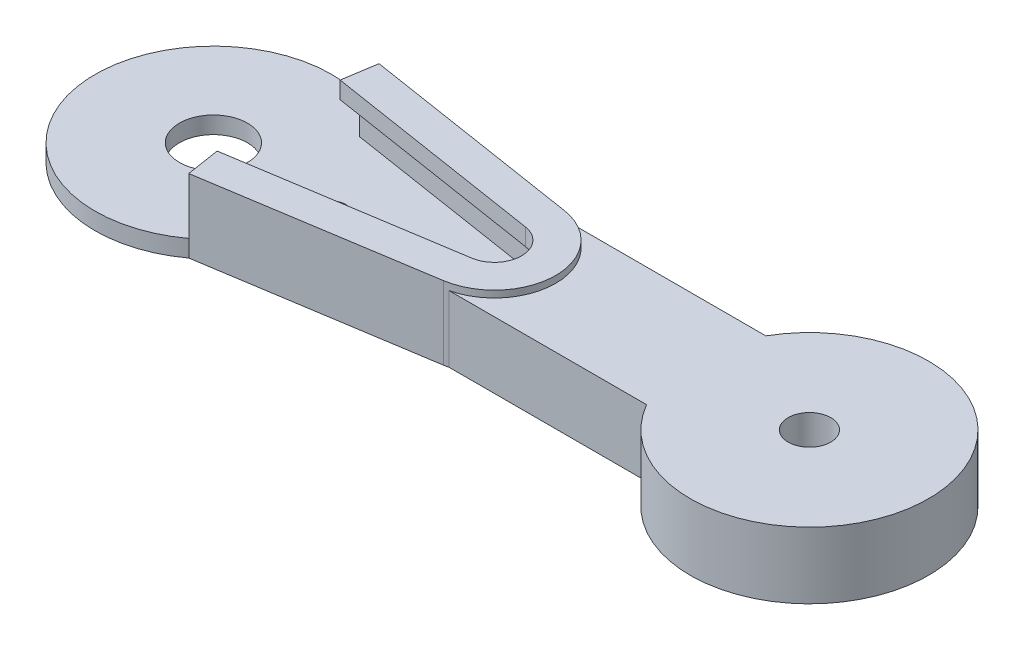
from build123d import *
from build123d.topology import SkipClean

# Parameters (mm, degrees)
SKETCH2_R           = 6
SKETCH2_R_2         = 1.5
BOSS_EXTRUDE1_DEPTH = 1.15
SKETCH3_R           = 4.4
BOSS_EXTRUDE2_DEPTH = 3.2
SKETCH4_R           = 0.75
BOSS_EXTRUDE3_DEPTH = 1.15
CIRPATTERN1_COUNT   = 2
BOSS_EXTRUDE5_DEPTH = 2.3
SKETCH7_R           = 2
BOSS_EXTRUDE6_DEPTH = 1
CUT_EXTRUDE2_DEPTH  = 23.239726126
CUT_EXTRUDE4_DEPTH  = 2.3
SKETCH13_R          = 4.4
CUT_EXTRUDE5_DEPTH  = 3.3
BOSS_EXTRUDE8_DEPTH = 1
SKETCH14_R          = 1.25
BOSS_EXTRUDE9_DEPTH = 3.9


with BuildPart() as part:
    # Sketch2 → Boss-Extrude1 (new, symmetric)
    with BuildSketch(Plane(origin=(0, 0, 0), x_dir=(1, 0, 0), z_dir=(0, 1, 0))):
        with Locations(Location((0, 0, 0), (0, 0, 270))):
            Circle(SKETCH2_R)
        with Locations(Location((0, 0, 0), (0, 0, 270))):
            Circle(SKETCH2_R_2, mode=Mode.SUBTRACT)
    extrude(amount=BOSS_EXTRUDE1_DEPTH, both=True)

    # Sketch3 → Boss-Extrude2 (add)
    with BuildSketch(Plane(origin=(0, 1.15, 0), x_dir=(1, 0, 0), z_dir=(0, 1, 0))):
        with Locations(Location((0, 0, 0), (0, 0, 270))):
            Circle(SKETCH3_R)
        with BuildLine():
            Line((0.107421435, 2.898009771), (0.338399731, 2.678709694))
            Line((0.338399731, 2.678709694), (0.61665913, 2.83367809))
            ThreePointArc((0.61665913, 2.83367809), (0.721200673, 2.808891167), (0.824752316, 2.780248841))
            Line((0.824752316, 2.780248841), (0.993936292, 2.510396512))
            Line((0.993936292, 2.510396512), (1.301992734, 2.591295993))
            ThreePointArc((1.301992734, 2.591295993), (1.397085655, 2.541289372), (1.490260976, 2.48779465))
            Line((1.490260976, 2.48779465), (1.587020181, 2.184345885))
            Line((1.587020181, 2.184345885), (1.905517346, 2.186093238))
            ThreePointArc((1.905517346, 2.186093238), (1.985186607, 2.11400902), (2.062131058, 2.039023173))
            Line((2.062131058, 2.039023173), (2.080385755, 1.721044772))
            Line((2.080385755, 1.721044772), (2.389311295, 1.643530205))
            ThreePointArc((2.389311295, 1.643530205), (2.448550984, 1.553897705), (2.504429862, 1.46213237))
            Line((2.504429862, 1.46213237), (2.443033042, 1.149604087))
            Line((2.443033042, 1.149604087), (2.722976028, 0.997698125))
            ThreePointArc((2.722976028, 0.997698125), (2.758063897, 0.896149284), (2.789366126, 0.793370413))
            Line((2.789366126, 0.793370413), (2.652175577, 0.505929549))
            Line((2.652175577, 0.505929549), (2.885546163, 0.289177003))
            ThreePointArc((2.885546163, 0.289177003), (2.894277512, 0.182092507), (2.899036259, 0.074758075))
            Line((2.899036259, 0.074758075), (2.694672167, -0.169534403))
            Line((2.694672167, -0.169534403), (2.866806821, -0.437514174))
            ThreePointArc((2.866806821, -0.437514174), (2.848633027, -0.543405812), (2.826549281, -0.648551587))
            Line((2.826549281, -0.648551587), (2.567852594, -0.834345885))
            Line((2.567852594, -0.834345885), (2.667935462, -1.136714727))
            ThreePointArc((2.667935462, -1.136714727), (2.623998452, -1.234759946), (2.576459817, -1.331110368))
            Line((2.576459817, -1.331110368), (2.279685399, -1.446732346))
            Line((2.279685399, -1.446732346), (2.301427906, -1.764491312))
            ThreePointArc((2.301427906, -1.764491312), (2.234488404, -1.84852957), (2.164481907, -1.930030589))
            Line((2.164481907, -1.930030589), (1.848277186, -1.968215294))
            Line((1.848277186, -1.968215294), (1.790313171, -2.281398419))
            ThreePointArc((1.790313171, -2.281398419), (1.704577232, -2.346149284), (1.616501638, -2.40767989))
            Line((1.616501638, -2.40767989), (1.30073492, -2.366028036))
            Line((1.30073492, -2.366028036), (1.166706475, -2.654956874))
            ThreePointArc((1.166706475, -2.654956874), (1.067561203, -2.696351809), (0.966950626, -2.734045809))
            Line((0.966950626, -2.734045809), (0.671462695, -2.615174535))
            Line((0.671462695, -2.615174535), (0.469791321, -2.861694623))
            ThreePointArc((0.469791321, -2.861694623), (0.363466377, -2.877132634), (0.25664255, -2.888621575))
            Line((0.25664255, -2.888621575), (0, -2.7))
            Line((0, -2.7), (-0.25664255, -2.888621575))
            ThreePointArc((-0.25664255, -2.888621575), (-0.363466377, -2.877132634), (-0.469791321, -2.861694623))
            Line((-0.469791321, -2.861694623), (-0.671462695, -2.615174535))
            Line((-0.671462695, -2.615174535), (-0.966950626, -2.734045809))
            ThreePointArc((-0.966950626, -2.734045809), (-1.067561203, -2.696351809), (-1.166706475, -2.654956874))
            Line((-1.166706475, -2.654956874), (-1.30073492, -2.366028036))
            Line((-1.30073492, -2.366028036), (-1.616501638, -2.40767989))
            ThreePointArc((-1.616501638, -2.40767989), (-1.704577232, -2.346149284), (-1.790313171, -2.281398419))
            Line((-1.790313171, -2.281398419), (-1.848277186, -1.968215294))
            Line((-1.848277186, -1.968215294), (-2.164481907, -1.930030589))
            ThreePointArc((-2.164481907, -1.930030589), (-2.234488404, -1.84852957), (-2.301427906, -1.764491312))
            Line((-2.301427906, -1.764491312), (-2.279685399, -1.446732346))
            Line((-2.279685399, -1.446732346), (-2.576459817, -1.331110368))
            ThreePointArc((-2.576459817, -1.331110368), (-2.623998452, -1.234759946), (-2.667935462, -1.136714727))
            Line((-2.667935462, -1.136714727), (-2.567852594, -0.834345885))
            Line((-2.567852594, -0.834345885), (-2.826549281, -0.648551587))
            ThreePointArc((-2.826549281, -0.648551587), (-2.848633027, -0.543405812), (-2.866806821, -0.437514174))
            Line((-2.866806821, -0.437514174), (-2.694672167, -0.169534403))
            Line((-2.694672167, -0.169534403), (-2.899036259, 0.074758075))
            ThreePointArc((-2.899036259, 0.074758075), (-2.894277512, 0.182092507), (-2.885546163, 0.289177003))
            Line((-2.885546163, 0.289177003), (-2.652175577, 0.505929549))
            Line((-2.652175577, 0.505929549), (-2.789366126, 0.793370413))
            ThreePointArc((-2.789366126, 0.793370413), (-2.758063897, 0.896149284), (-2.722976028, 0.997698125))
            Line((-2.722976028, 0.997698125), (-2.443033042, 1.149604087))
            Line((-2.443033042, 1.149604087), (-2.504429862, 1.46213237))
            ThreePointArc((-2.504429862, 1.46213237), (-2.448550984, 1.553897705), (-2.389311295, 1.643530205))
            Line((-2.389311295, 1.643530205), (-2.080385755, 1.721044772))
            Line((-2.080385755, 1.721044772), (-2.062131058, 2.039023173))
            ThreePointArc((-2.062131058, 2.039023173), (-1.985186607, 2.11400902), (-1.905517346, 2.186093238))
            Line((-1.905517346, 2.186093238), (-1.587020181, 2.184345885))
            Line((-1.587020181, 2.184345885), (-1.490260976, 2.48779465))
            ThreePointArc((-1.490260976, 2.48779465), (-1.397085655, 2.541289372), (-1.301992734, 2.591295993))
            Line((-1.301992734, 2.591295993), (-0.993936292, 2.510396512))
            Line((-0.993936292, 2.510396512), (-0.824752316, 2.780248841))
            ThreePointArc((-0.824752316, 2.780248841), (-0.721200673, 2.808891167), (-0.61665913, 2.83367809))
            Line((-0.61665913, 2.83367809), (-0.338399731, 2.678709694))
            Line((-0.338399731, 2.678709694), (-0.107421435, 2.898009771))
            ThreePointArc((-0.107421435, 2.898009771), (0, 2.9), (0.107421435, 2.898009771))
        make_face(mode=Mode.SUBTRACT)
    extrude(amount=BOSS_EXTRUDE2_DEPTH)

    # Sketch4 → Boss-Extrude3 (add, symmetric)
    with BuildSketch(Plane(origin=(0, 0, 0), x_dir=(1, 0, 0), z_dir=(0, 1, 0))):
        with BuildLine():
            Line((3.968626967, 4.5), (16.888114198, 2.469689731))
            ThreePointArc((16.888114198, 2.469689731), (19, 0), (16.888114198, -2.469689731))
            Line((16.888114198, -2.469689731), (3.968626967, -4.5))
            ThreePointArc((3.968626967, -4.5), (6, 0), (3.968626967, 4.5))
        make_face()
        with Locations(Location((16, 0, 0), (0, 0, 270))):
            Circle(SKETCH4_R, mode=Mode.SUBTRACT)
        with Locations(Location((13, 0, 0), (0, 0, 270))):
            Circle(SKETCH4_R, mode=Mode.SUBTRACT)
        with Locations(Location((10, 0, 0), (0, 0, 270))):
            Circle(SKETCH4_R, mode=Mode.SUBTRACT)
        with Locations(Location((7, 0, 0), (0, 0, 270))):
            Circle(SKETCH4_R, mode=Mode.SUBTRACT)
    boss_extrude3 = extrude(amount=BOSS_EXTRUDE3_DEPTH, both=True)

    # CirPattern1: Boss-Extrude3 ×2 about axis
    cirpattern1_axis = Axis((0, 0, 0), (0, 1, 0))
    for i in range(1, CIRPATTERN1_COUNT):
        add(boss_extrude3.rotate(cirpattern1_axis, i * 360 / CIRPATTERN1_COUNT))



with BuildPart() as body_2:
    # Sketch6 → Boss-Extrude5 (new body)
    with BuildSketch(Plane.XZ.offset(1.15)):
        with BuildLine():
            Line((17.058884445, -3.556353213), (4.139397214, -5.586663482))
            Line((4.139397214, -5.586663482), (3.984151535, -4.598787589))
            Line((3.984151535, -4.598787589), (16.903638766, -2.568477321))
            ThreePointArc((16.903638766, -2.568477321), (19.1, 0), (16.903638766, 2.568477321))
            Line((16.903638766, 2.568477321), (3.984151535, 4.598787589))
            Line((3.984151535, 4.598787589), (4.139397214, 5.586663482))
            Line((4.139397214, 5.586663482), (17.058884445, 3.556353213))
            ThreePointArc((17.058884445, 3.556353213), (20.1, 0), (17.058884445, -3.556353213))
        make_face()
    extrude(amount=-BOSS_EXTRUDE5_DEPTH)


with BuildPart() as part_1:
    add(part.part)

    add(body_2.part)  # Boss-Extrude6 merges body 2
    # Sketch7 → Boss-Extrude6 (add)
    with BuildSketch(Plane.XZ.offset(1.15)):
        with BuildLine():
            Line((4.139397214, -5.586663482), (17.058884445, -3.556353213))
            ThreePointArc((17.058884445, -3.556353213), (20.1, 0), (17.058884445, 3.556353213))
            Line((17.058884445, 3.556353213), (4.139397214, 5.586663482))
            ThreePointArc((4.139397214, 5.586663482), (-6.953086951, 0), (4.139397214, -5.586663482))
        make_face()
        with Locations(Location((0, 0, 0), (0, 0, 270))):
            Circle(SKETCH7_R, mode=Mode.SUBTRACT)
    extrude(amount=BOSS_EXTRUDE6_DEPTH)

    # Sketch10 → Cut-Extrude2 (cut, through all)
    with SkipClean():  # the faces are left unmerged after this step: merging them gives an invalid solid
        with BuildSketch(Plane.XZ.offset(2.15)):
            with BuildLine():
                ThreePointArc((10.75, 0), (10, 0.75), (9.25, 0))
                Line((9.25, 0), (10.75, 0))
            make_face()
            with BuildLine():
                Line((10.75, 0), (9.25, 0))
                ThreePointArc((9.25, 0), (10, -0.75), (10.75, 0))
            make_face()
            with BuildLine():
                ThreePointArc((13.75, 0), (13, 0.75), (12.25, 0))
                Line((12.25, 0), (13.75, 0))
            make_face()
            with BuildLine():
                Line((13.75, 0), (12.25, 0))
                ThreePointArc((12.25, 0), (13, -0.75), (13.75, 0))
            make_face()
            with BuildLine():
                ThreePointArc((16.75, 0), (16, 0.75), (15.25, 0))
                Line((15.25, 0), (16.75, 0))
            make_face()
            with BuildLine():
                Line((16.75, 0), (15.25, 0))
                ThreePointArc((15.25, 0), (16, -0.75), (16.75, 0))
            make_face()
            with BuildLine():
                ThreePointArc((7.75, 0), (7, 0.75), (6.25, 0))
                Line((6.25, 0), (7.75, 0))
            make_face()
            with BuildLine():
                Line((7.75, 0), (6.25, 0))
                ThreePointArc((6.25, 0), (7, -0.75), (7.75, 0))
            make_face()
        extrude(amount=-CUT_EXTRUDE2_DEPTH, mode=Mode.SUBTRACT)

    # Sketch12 → Cut-Extrude4 (cut)
    with BuildSketch(Plane(origin=(0, 1.15, 0), x_dir=(1, 0, 0), z_dir=(0, 1, 0))):
        with BuildLine():
            Line((-3.968626967, 4.5), (-16.888114198, 2.469689731))
            ThreePointArc((-16.888114198, 2.469689731), (-19, 0), (-16.888114198, -2.469689731))
            Line((-16.888114198, -2.469689731), (-3.968626967, -4.5))
            ThreePointArc((-3.968626967, -4.5), (0, -6), (3.968626967, -4.5))
            Line((3.968626967, -4.5), (16.888114198, -2.469689731))
            ThreePointArc((16.888114198, -2.469689731), (19, 0), (16.888114198, 2.469689731))
            Line((16.888114198, 2.469689731), (3.968626967, 4.5))
            ThreePointArc((3.968626967, 4.5), (0, 6), (-3.968626967, 4.5))
        make_face()
    extrude(amount=-CUT_EXTRUDE4_DEPTH, mode=Mode.SUBTRACT)


with BuildPart() as cut_extrude4_piece_1:
    # of the separate pieces the step leaves, piece 1, a body of its own (cut_extrude4_pieces)
    add(part_1.part.solids().sort_by_distance((4.139397214, -1.15, -5.586663482))[0])

    # Sketch9 → Boss-Extrude8 (add)
    with BuildSketch(Plane(origin=(0, 1.15, 0), x_dir=(1, 0, 0), z_dir=(0, 1, 0))):
        with BuildLine():
            ThreePointArc((17.058884445, -3.556353213), (20.1, 0), (17.058884445, 3.556353213))
            Line((17.058884445, 3.556353213), (4.139397214, 5.586663482))
            Line((4.139397214, 5.586663482), (3.984151535, 4.598787589))
            Line((3.984151535, 4.598787589), (16.903638766, 2.568477321))
            ThreePointArc((16.903638766, 2.568477321), (19.1, 0), (16.903638766, -2.568477321))
            Line((16.903638766, -2.568477321), (3.984151535, -4.598787589))
            Line((3.984151535, -4.598787589), (4.139397214, -5.586663482))
            Line((4.139397214, -5.586663482), (17.058884445, -3.556353213))
        make_face()
        with BuildLine():
            ThreePointArc((16.748393087, -1.580601428), (18.1, 0), (16.748393087, 1.580601428))
            Line((16.748393087, 1.580601428), (3.828905855, 3.610911697))
            Line((3.828905855, 3.610911697), (3.984151535, 4.598787589))
            Line((3.984151535, 4.598787589), (16.903638766, 2.568477321))
            ThreePointArc((16.903638766, 2.568477321), (19.1, 0), (16.903638766, -2.568477321))
            Line((16.903638766, -2.568477321), (3.984151535, -4.598787589))
            Line((3.984151535, -4.598787589), (3.828905855, -3.610911697))
            Line((3.828905855, -3.610911697), (16.748393087, -1.580601428))
        make_face()
    extrude(amount=BOSS_EXTRUDE8_DEPTH)

    # Sketch14 → Boss-Extrude9 (add)
    # profile 1 of 5: a face of its own
    with BuildSketch(Plane.XZ.offset(2.15)):
        with BuildLine():
            Line((28, 0), (20.1, 0))
            ThreePointArc((20.1, 0), (19.327844932, -2.227844932), (17.342614977, -3.5))
            Line((17.342614977, -3.5), (28.937822174, -3.5))
            ThreePointArc((28.937822174, -3.5), (28.238519216, -1.811733316), (28, 0))
        make_face()
    # profile 2 of 5: a face of its own
    with BuildSketch(Plane.XZ.offset(2.15)):
        with BuildLine():
            ThreePointArc((17.342614977, 3.5), (19.327844932, 2.227844932), (20.1, 0))
            Line((20.1, 0), (28, 0))
            ThreePointArc((28, 0), (28.238519216, 1.811733316), (28.937822174, 3.5))
            Line((28.937822174, 3.5), (17.342614977, 3.5))
        make_face()
    # profile 3 of 5: a face of its own
    with BuildSketch(Plane.XZ.offset(2.15)):
        with BuildLine():
            Line((30.836953373, 3.5), (30.836953373, 0))
            Line((30.836953373, 0), (30.836953373, -3.5))
            Line((30.836953373, -3.5), (28.937822174, -3.5))
            ThreePointArc((28.937822174, -3.5), (36.811733316, -6.761480784), (42, 0))
            ThreePointArc((42, 0), (36.811733316, 6.761480784), (28.937822174, 3.5))
            Line((28.937822174, 3.5), (30.836953373, 3.5))
        make_face()
        with Locations(Location((35, 0, 0), (0, 0, 270))):
            Circle(SKETCH14_R, mode=Mode.SUBTRACT)
    # profile 4 of 5: a face of its own
    with BuildSketch(Plane.XZ.offset(2.15)):
        with BuildLine():
            Line((30.836953373, 0), (28, 0))
            ThreePointArc((28, 0), (28.238519216, -1.811733316), (28.937822174, -3.5))
            Line((28.937822174, -3.5), (30.836953373, -3.5))
            Line((30.836953373, -3.5), (30.836953373, 0))
        make_face()
    # profile 5 of 5: a face of its own
    with BuildSketch(Plane.XZ.offset(2.15)):
        with BuildLine():
            ThreePointArc((28.937822174, 3.5), (28.238519216, 1.811733316), (28, 0))
            Line((28, 0), (30.836953373, 0))
            Line((30.836953373, 0), (30.836953373, 3.5))
            Line((30.836953373, 3.5), (28.937822174, 3.5))
        make_face()
    extrude(amount=-BOSS_EXTRUDE9_DEPTH)


with BuildPart() as cut_extrude4_piece_2:
    # of the separate pieces the step leaves, piece 2, a body of its own (cut_extrude4_pieces)
    add(part_1.part.solids().sort_by_distance((0, 1.15, 4.4))[0])

    # Sketch13 → Cut-Extrude5 (cut)
    with BuildSketch(Plane(origin=(0, 4.35, 0), x_dir=(1, 0, 0), z_dir=(0, 1, 0))):
        Circle(SKETCH13_R)
    extrude(amount=-CUT_EXTRUDE5_DEPTH, mode=Mode.SUBTRACT)


solid = cut_extrude4_piece_1.part
